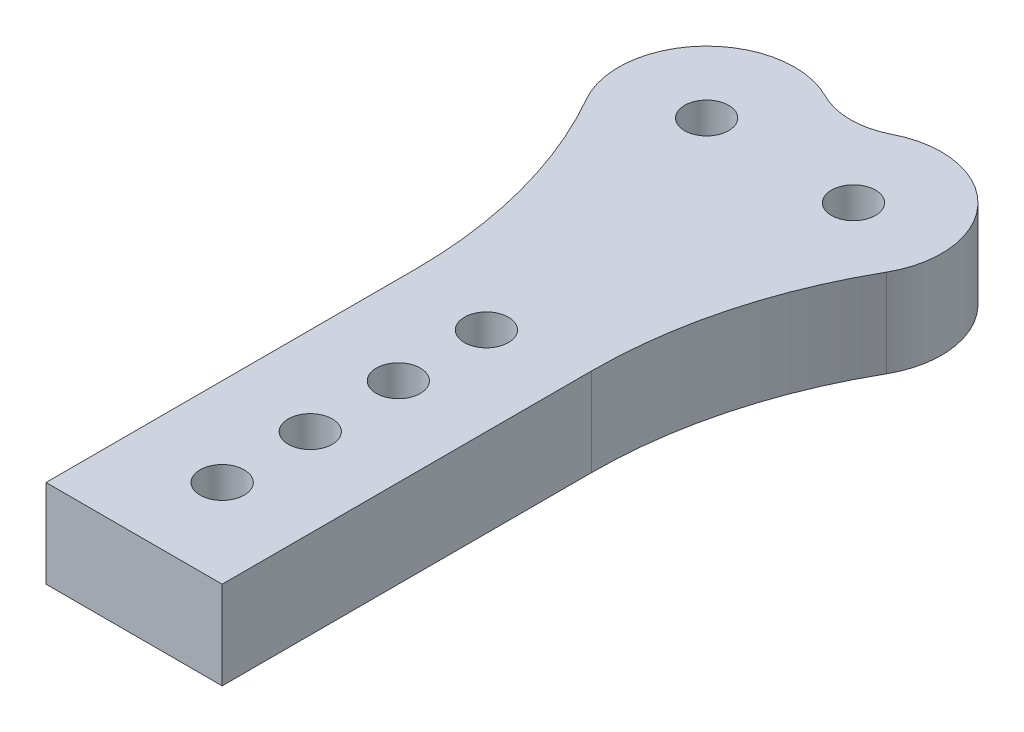
from build123d import *

# Parameters (mm, degrees)
CROQUIS2_W              = 6
CROQUIS2_H              = 22
SALIENTE_EXTRUIR2_DEPTH = 3
CROQUIS7_R              = 3
SALIENTE_EXTRUIR4_DEPTH = 3
REDONDEO2_R             = 2.5
CROQUIS11_R             = 0.75
CORTAR_EXTRUIR6_DEPTH   = 3
CROQUIS12_R             = 0.75
CORTAR_EXTRUIR7_DEPTH   = 10
REDONDEO3_R             = 16


with BuildPart() as part:
    # Croquis2 → Saliente-Extruir2 (new body)
    with BuildSketch(Plane(origin=(0, 0, 0), x_dir=(1, 0, 0), z_dir=(0, 1, 0))):
        with Locations((-13.931432693, -12.112220068)):
            Rectangle(CROQUIS2_W, CROQUIS2_H)
    extrude(amount=SALIENTE_EXTRUIR2_DEPTH)

    # Croquis7 → Saliente-Extruir4 (add)
    with BuildSketch(Plane(origin=(0, 3, 0), x_dir=(1, 0, 0), z_dir=(0, 1, 0))):
        with Locations((-16.431432693, -1.112220068)):
            Circle(CROQUIS7_R)
        with Locations((-11.431432693, -1.112220068)):
            Circle(CROQUIS7_R)
    extrude(amount=-SALIENTE_EXTRUIR4_DEPTH)

    # Redondeo2
    redondeo2_edges = [part.edges().sort_by_distance(p)[0] for p in [
        (-13.931432693, 1.5, -0.546092328),
    ]]
    fillet(redondeo2_edges, radius=REDONDEO2_R)

    # Croquis11 → Cortar-Extruir6 (cut)
    with BuildSketch(Plane(origin=(0, 3, 0), x_dir=(1, 0, 0), z_dir=(0, 1, 0))):
        with Locations((-16.431432693, -1.112220068)):
            Circle(CROQUIS11_R)
        with Locations((-11.431432693, -1.112220068)):
            Circle(CROQUIS11_R)
    extrude(amount=-CORTAR_EXTRUIR6_DEPTH, mode=Mode.SUBTRACT)

    # Croquis12 → Cortar-Extruir7 (cut)
    with BuildSketch(Plane.XZ):
        with Locations((-13.931432693, 20.112220068)):
            Circle(CROQUIS12_R)
        with Locations((-13.931432693, 17.112220068)):
            Circle(CROQUIS12_R)
        with Locations((-13.931432693, 14.112220068)):
            Circle(CROQUIS12_R)
        with Locations((-13.931432693, 11.112220068)):
            Circle(CROQUIS12_R)
    extrude(amount=-CORTAR_EXTRUIR7_DEPTH, mode=Mode.SUBTRACT)

    # Redondeo3
    redondeo3_edges = [part.edges().sort_by_distance(p)[0] for p in [
        (-10.931432693, 1.5, 4.070259959),
        (-16.931432693, 1.5, 4.070259959),
    ]]
    fillet(redondeo3_edges, radius=REDONDEO3_R)


solid = part.part
